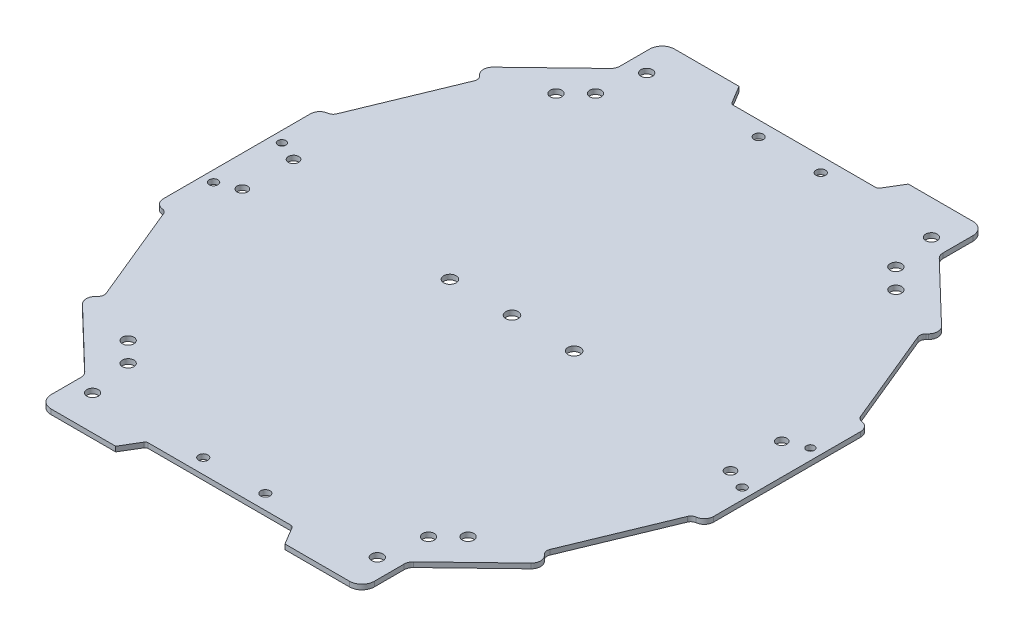
from build123d import *

# Parameters (mm, degrees)
SKETCH1_R        = 1.85915493
SKETCH1_R_2      = 2
SKETCH1_R_3      = 1.28892694
SKETCH1_R_4      = 1.407234354
SKETCH1_R_5      = 1.5
SKETCH1_R_6      = 1.673239437
EXTRUSION1_DEPTH = 1.6
FILLET1_R        = 1
FILLET2_R        = 4
FILLET3_R        = 3
FILLET4_R        = 3
FILLET5_R        = 2
FILLET6_R        = 2
FILLET7_R        = 3
FILLET8_R        = 3
FILLET9_R        = 2
FILLET10_R       = 2
FILLET11_R       = 3


with BuildPart() as part:
    # Sketch1 → Extrusion1 (new body)
    with BuildSketch(Plane(origin=(0, 0, 0), x_dir=(-1, 0, 0), z_dir=(0, 1, 0))):
        Polygon((74.087520418, 321.088295015), (70.369210559, 327.285477572), (45.580478165, 327.285477572), (45.580478165, 312.412238135), (23.246043749, 290.934342561), (26.682507041, 287.360833055), (12.735407819, 253.538985229), (9.017097883, 253.538985229), (9.017097883, 226.891111382), (9.017097883, 200.243237534), (12.735407819, 200.243237534), (26.682507041, 166.421389708), (23.246043749, 162.847880202), (45.580478165, 141.369984628), (45.580478165, 126.496745191), (70.369210559, 126.496745191), (74.087520418, 132.693927748), (97.636816193, 132.693927748), (121.186111968, 132.693927748), (124.904421827, 126.496745191), (149.693154221, 126.496745191), (149.693154221, 141.369984628), (172.027588636, 162.847880202), (168.591125345, 166.421389708), (182.538224567, 200.243237534), (186.256534503, 200.243237534), (186.256534503, 226.891111382), (186.256534503, 253.538985229), (182.538224567, 253.538985229), (168.591125345, 287.360833055), (172.027588636, 290.934342561), (149.693154221, 312.412238135), (149.693154221, 327.285477572), (124.904421827, 327.285477572), (121.186111968, 321.088295015), (97.636816193, 321.088295015), align=None)
        with Locations((49.266182018, 151.62213525)):
            Circle(SKETCH1_R, mode=Mode.SUBTRACT)
        with Locations((117.636816193, 226.891111382)):
            Circle(SKETCH1_R_2, mode=Mode.SUBTRACT)
        with Locations((77.636816193, 226.891111382)):
            Circle(SKETCH1_R_2, mode=Mode.SUBTRACT)
        with Locations((97.636816193, 226.891111382)):
            Circle(SKETCH1_R_2, mode=Mode.SUBTRACT)
        with Locations((12.517097883, 215.891111382)):
            Circle(SKETCH1_R_3, mode=Mode.SUBTRACT)
        with Locations((12.517097883, 237.891111382)):
            Circle(SKETCH1_R_4, mode=Mode.SUBTRACT)
        with Locations((107.636816193, 316.338295015)):
            Circle(SKETCH1_R_5, mode=Mode.SUBTRACT)
        with Locations((87.636816193, 316.338295015)):
            Circle(SKETCH1_R_5, mode=Mode.SUBTRACT)
        with Locations((87.636816193, 137.443927748)):
            Circle(SKETCH1_R_5, mode=Mode.SUBTRACT)
        with Locations((107.636816193, 137.443927748)):
            Circle(SKETCH1_R_5, mode=Mode.SUBTRACT)
        with Locations((182.756534503, 215.891111382)):
            Circle(SKETCH1_R_3, mode=Mode.SUBTRACT)
        with Locations((182.756534503, 237.891111382)):
            Circle(SKETCH1_R_4, mode=Mode.SUBTRACT)
        with Locations((176.256534503, 235.141111382)):
            Circle(SKETCH1_R_6, mode=Mode.SUBTRACT)
        with Locations((176.256534503, 218.641111382)):
            Circle(SKETCH1_R_6, mode=Mode.SUBTRACT)
        with Locations((51.777661187, 316.130534525)):
            Circle(SKETCH1_R, mode=Mode.SUBTRACT)
        with Locations((49.266182018, 302.160087513)):
            Circle(SKETCH1_R, mode=Mode.SUBTRACT)
        with Locations((19.017097883, 235.141111382)):
            Circle(SKETCH1_R_6, mode=Mode.SUBTRACT)
        with Locations((143.495971199, 137.651688238)):
            Circle(SKETCH1_R, mode=Mode.SUBTRACT)
        with Locations((146.007450368, 151.62213525)):
            Circle(SKETCH1_R, mode=Mode.SUBTRACT)
        with Locations((143.495971199, 316.130534525)):
            Circle(SKETCH1_R, mode=Mode.SUBTRACT)
        with Locations((146.007450368, 302.160087513)):
            Circle(SKETCH1_R, mode=Mode.SUBTRACT)
        with Locations((19.017097883, 218.641111382)):
            Circle(SKETCH1_R_6, mode=Mode.SUBTRACT)
        with Locations((51.777661187, 137.651688238)):
            Circle(SKETCH1_R, mode=Mode.SUBTRACT)
        with Locations((42.888078851, 158.000238416)):
            Circle(SKETCH1_R, mode=Mode.SUBTRACT)
        with Locations((152.385553534, 295.781984347)):
            Circle(SKETCH1_R, mode=Mode.SUBTRACT)
        with Locations((42.888078851, 295.781984347)):
            Circle(SKETCH1_R, mode=Mode.SUBTRACT)
        with Locations((152.385553534, 158.000238416)):
            Circle(SKETCH1_R, mode=Mode.SUBTRACT)
    extrude(amount=EXTRUSION1_DEPTH)

    # Fillet1
    fillet1_edges = [part.edges().sort_by_distance(p)[0] for p in [
        (-121.186111968, 0.8, 321.088295015),
        (-121.186111968, 0.8, 132.693927748),
        (-74.087520418, 0.8, 132.693927748),
        (-74.087520418, 0.8, 321.088295015),
    ]]
    fillet(fillet1_edges, radius=FILLET1_R)

    # Fillet2
    fillet2_edges = [part.edges().sort_by_distance(p)[0] for p in [
        (-149.693154221, 0.8, 327.285477572),
        (-149.693154221, 0.8, 126.496745191),
        (-45.580478165, 0.8, 126.496745191),
        (-45.580478165, 0.8, 327.285477572),
    ]]
    fillet(fillet2_edges, radius=FILLET2_R)

    # Fillet3
    fillet3_edges = [part.edges().sort_by_distance(p)[0] for p in [
        (-149.693154221, 0.8, 312.412238135),
        (-149.693154221, 0.8, 141.369984628),
        (-45.580478165, 0.8, 141.369984628),
        (-45.580478165, 0.8, 312.412238135),
    ]]
    fillet(fillet3_edges, radius=FILLET3_R)

    # Fillet4
    fillet4_edges = [part.edges().sort_by_distance(p)[0] for p in [
        (-172.027588636, 0.8, 290.934342561),
    ]]
    fillet(fillet4_edges, radius=FILLET4_R)

    # Fillet5
    fillet5_edges = [part.edges().sort_by_distance(p)[0] for p in [
        (-168.591125345, 0.8, 287.360833055),
    ]]
    fillet(fillet5_edges, radius=FILLET5_R)

    # Fillet6
    fillet6_edges = [part.edges().sort_by_distance(p)[0] for p in [
        (-26.682507041, 0.8, 287.360833055),
    ]]
    fillet(fillet6_edges, radius=FILLET6_R)

    # Fillet7
    fillet7_edges = [part.edges().sort_by_distance(p)[0] for p in [
        (-23.246043749, 0.8, 290.934342561),
    ]]
    fillet(fillet7_edges, radius=FILLET7_R)

    # Fillet8
    fillet8_edges = [part.edges().sort_by_distance(p)[0] for p in [
        (-172.027588636, 0.8, 162.847880202),
        (-23.246043749, 0.8, 162.847880202),
    ]]
    fillet(fillet8_edges, radius=FILLET8_R)

    # Fillet9
    fillet9_edges = [part.edges().sort_by_distance(p)[0] for p in [
        (-168.591125345, 0.8, 166.421389708),
        (-26.682507041, 0.8, 166.421389708),
    ]]
    fillet(fillet9_edges, radius=FILLET9_R)

    # Fillet10
    fillet10_edges = [part.edges().sort_by_distance(p)[0] for p in [
        (-182.538224567, 0.8, 253.538985229),
        (-182.538224567, 0.8, 200.243237534),
        (-12.735407819, 0.8, 200.243237534),
        (-12.735407819, 0.8, 253.538985229),
    ]]
    fillet(fillet10_edges, radius=FILLET10_R)

    # Fillet11
    fillet11_edges = [part.edges().sort_by_distance(p)[0] for p in [
        (-186.256534503, 0.8, 200.243237534),
        (-186.256534503, 0.8, 253.538985229),
        (-9.017097883, 0.8, 253.538985229),
        (-9.017097883, 0.8, 200.243237534),
    ]]
    fillet(fillet11_edges, radius=FILLET11_R)


solid = part.part
